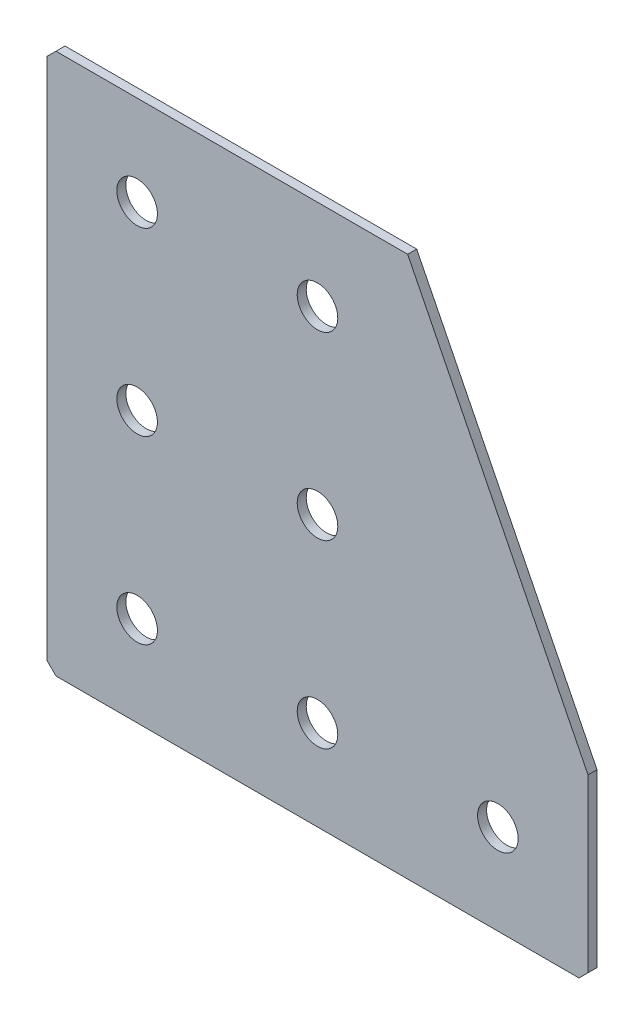
from build123d import *

# Parameters (mm, degrees)
EXTRUDE_1_DEPTH   = 2
HOLE_WIZARD_M81_D = 9
CHAMFER_1_SIZE    = 2


with BuildPart() as part:
    # Эскиз1 → Бобышка-Вытянуть1 (new body)
    with BuildSketch(Plane(origin=(0, 0, 0), x_dir=(1, 0, 0), z_dir=(0, 0, -1))):
        Polygon((0, 0), (0, 120), (120, 120), (120, 80), (80, 0), align=None)
    extrude(amount=EXTRUDE_1_DEPTH)

    # Отверстие с зазором M81 (through all)
    with Locations(Plane(origin=(0, 0, -2), x_dir=(1, 0, 0), z_dir=(0, 0, -1))):
        with Locations((60, 100), (20, 100), (20, 60), (20, 20), (100, 100), (60, 60), (60, 20)):
            Hole(HOLE_WIZARD_M81_D / 2)

    # Фаска1
    chamfer_1_edges = [part.edges().sort_by_distance(p)[0] for p in [
        (0, 0, -1),
        (0, -120, -1),
        (120, -120, -1),
    ]]
    chamfer(chamfer_1_edges, length=CHAMFER_1_SIZE)


solid = part.part
